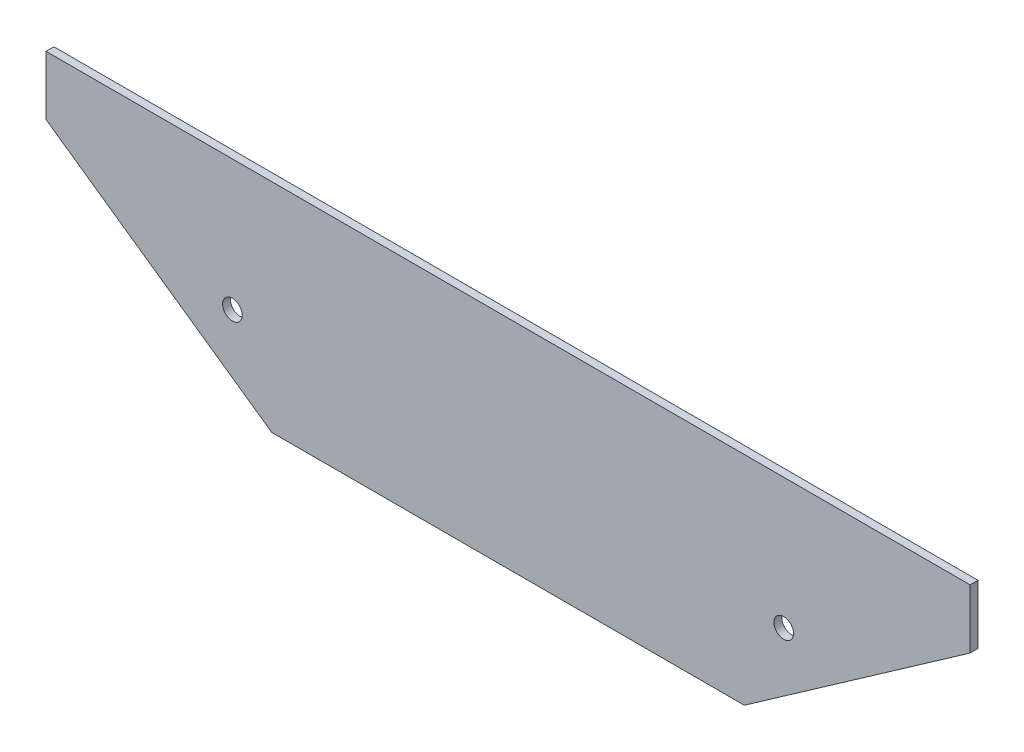
from build123d import *

# Parameters (mm, degrees)
SKETCH1_R           = 2.5
BOSS_EXTRUDE1_DEPTH = 2
CUT_EXTRUDE1_DEPTH  = 10


with BuildPart() as part:
    # Sketch1 → Boss-Extrude1 (new body)
    with BuildSketch(Plane.XY.offset(92)):
        Polygon((26.130057398, -8.597379557), (26.130057398, -23.597379557), (83.470700498, -63.747730101), (402.6593569, -63.747730101), (460, -23.597379557), (460, -8.597379557), align=None)
        with Locations((173.065028699, -41.747730101)):
            Circle(SKETCH1_R, mode=Mode.SUBTRACT)
        with Locations((313.065028699, -41.747730101)):
            Circle(SKETCH1_R, mode=Mode.SUBTRACT)
    extrude(amount=BOSS_EXTRUDE1_DEPTH)

    # Sketch2 → Cut-Extrude1 (cut)
    with BuildSketch(Plane(origin=(0, 0, 92), x_dir=(-1, 0, 0), z_dir=(0, 0, -1))):
        Polygon((-381.8278919, -8.597379557), (-360.405671799, -23.597379557), (-360.405671799, -8.597379557), align=None)
        Polygon((-303.065028699, -63.747730101), (-360.405671799, -23.597379557), (-381.8278919, -8.597379557), (-460, -8.597379557), (-460, -23.597379557), (-402.6593569, -63.747730101), align=None)
        Polygon((-125.724385599, -8.597379557), (-125.724385599, -23.597379557), (-104.302165498, -8.597379557), align=None)
        Polygon((-104.302165498, -8.597379557), (-125.724385599, -23.597379557), (-183.065028699, -63.747730101), (-83.470700498, -63.747730101), (-26.130057398, -23.597379557), (-26.130057398, -8.597379557), align=None)
    extrude(amount=-CUT_EXTRUDE1_DEPTH, mode=Mode.SUBTRACT)


solid = part.part
